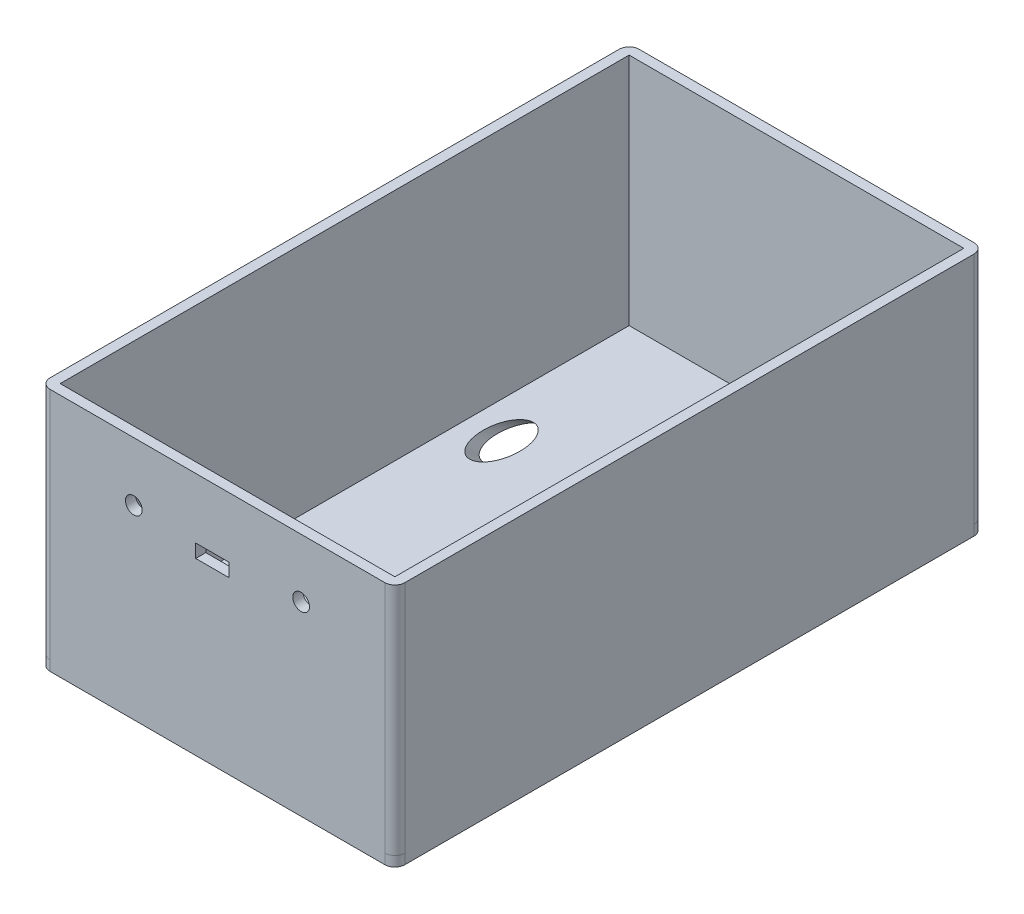
from build123d import *

# Parameters (mm, degrees)
ESQUISSE15_W             = 106
ESQUISSE15_H             = 176
ESQUISSE15_W_2           = 100
ESQUISSE15_H_2           = 170
BOSS_EXTRU_9_DEPTH       = 70
CONG_1_R                 = 3
ESQUISSE18_W             = 106
ESQUISSE18_H             = 176
BOSS_EXTRU_10_DEPTH      = 3
CONG_2_R                 = 3
ESQUISSE22_R             = 10.869506495
ENL_V_MAT_EXTRU_5_DEPTH  = 3
ESQUISSE23_W             = 14
ESQUISSE23_H             = 38
ENL_V_MAT_EXTRU_6_DEPTH  = 3
ESQUISSE24_W             = 3
ESQUISSE24_H             = 20
ENL_V_MAT_EXTRU_7_DEPTH  = 3
ESQUISSE26_R             = 2.5
ENL_V_MAT_EXTRU_11_DEPTH = 3
ESQUISSE28_W             = 13
ESQUISSE28_H             = 9
ENL_V_MAT_EXTRU_13_DEPTH = 3
D_GAGEMENT_03_D          = 10.9248
ESQUISSE43_W             = 10
ESQUISSE43_H             = 5
BOSS_EXTRU_11_DEPTH      = 3
ESQUISSE44_W             = 3
ESQUISSE44_H             = 9
BOSS_EXTRU_12_DEPTH      = 3


with BuildPart() as part:
    # Esquisse15 → Boss.-Extru.9 (new body)
    with BuildSketch(Plane(origin=(0, 0, 0), x_dir=(1, 0, 0), z_dir=(0, 1, 0))):
        Rectangle(ESQUISSE15_W, ESQUISSE15_H)
        Rectangle(ESQUISSE15_W_2, ESQUISSE15_H_2, mode=Mode.SUBTRACT)
    extrude(amount=BOSS_EXTRU_9_DEPTH)

    # Congé1
    cong_1_edges = [part.edges().sort_by_distance(p)[0] for p in [
        (-53, 35, -88),
        (53, 35, -88),
        (53, 35, 88),
        (-53, 35, 88),
    ]]
    fillet(cong_1_edges, radius=CONG_1_R)

    # Esquisse18 → Boss.-Extru.10 (add)
    with BuildSketch(Plane.XZ):
        Rectangle(ESQUISSE18_W, ESQUISSE18_H)
    extrude(amount=BOSS_EXTRU_10_DEPTH)

    # Congé2
    cong_2_edges = [part.edges().sort_by_distance(p)[0] for p in [
        (53, -1.5, 88),
        (53, -1.5, -88),
        (-53, -1.5, -88),
        (-53, -1.5, 88),
    ]]
    fillet(cong_2_edges, radius=CONG_2_R)

    # Esquisse22 → Enlèv. mat.-Extru.5 (cut)
    with BuildSketch(Plane(origin=(0, 0, 0), x_dir=(1, 0, 0), z_dir=(0, 1, 0))):
        with Locations((0, -60)):
            Circle(ESQUISSE22_R)
    extrude(amount=-ENL_V_MAT_EXTRU_5_DEPTH, mode=Mode.SUBTRACT)

    # Esquisse23 → Enlèv. mat.-Extru.6 (cut)
    with BuildSketch(Plane(origin=(0, 0, 0), x_dir=(1, 0, 0), z_dir=(0, 1, 0))):
        with Locations((30.434753248, -60)):
            Rectangle(ESQUISSE23_W, ESQUISSE23_H)
    extrude(amount=-ENL_V_MAT_EXTRU_6_DEPTH, mode=Mode.SUBTRACT)

    # Esquisse24 → Enlèv. mat.-Extru.7 (cut)
    with BuildSketch(Plane(origin=(0, 0, 0), x_dir=(1, 0, 0), z_dir=(0, 1, 0))):
        with Locations((-30.434753248, -60)):
            Rectangle(ESQUISSE24_W, ESQUISSE24_H)
    extrude(amount=-ENL_V_MAT_EXTRU_7_DEPTH, mode=Mode.SUBTRACT)

    # Esquisse26 → Enlèv. mat.-Extru.11 (cut)
    with BuildSketch(Plane(origin=(0, 0, 85), x_dir=(-1, 0, 0), z_dir=(0, 0, -1))):
        with Locations((-25, 52.5)):
            Circle(ESQUISSE26_R)
        with Locations((25, 52.5)):
            Circle(ESQUISSE26_R)
    extrude(amount=-ENL_V_MAT_EXTRU_11_DEPTH, mode=Mode.SUBTRACT)

    # Esquisse28 → Enlèv. mat.-Extru.13 (cut)
    with BuildSketch(Plane(origin=(0, 0, 85), x_dir=(-1, 0, 0), z_dir=(0, 0, -1))):
        with Locations((0, 52.5)):
            Rectangle(ESQUISSE28_W, ESQUISSE28_H)
    extrude(amount=-ENL_V_MAT_EXTRU_13_DEPTH, mode=Mode.SUBTRACT)

    # Dégagement #03 (through all)
    with Locations(Plane(origin=(-50, 70, 23.760275735), x_dir=(1, 0, 0), z_dir=(0, 0.573576436, 0.819152044))):
        with Locations((10.736336361, -22.988358748)):
            Hole(D_GAGEMENT_03_D / 2)

    # Esquisse43 → Boss.-Extru.11 (add)
    with BuildSketch(Plane.XY.offset(88)):
        with Locations((-1.5, 54.5)):
            Rectangle(ESQUISSE43_W, ESQUISSE43_H)
    extrude(amount=-BOSS_EXTRU_11_DEPTH)

    # Esquisse44 → Boss.-Extru.12 (add)
    with BuildSketch(Plane.XY.offset(88)):
        with Locations((5, 52.5)):
            Rectangle(ESQUISSE44_W, ESQUISSE44_H)
    extrude(amount=-BOSS_EXTRU_12_DEPTH)


solid = part.part
